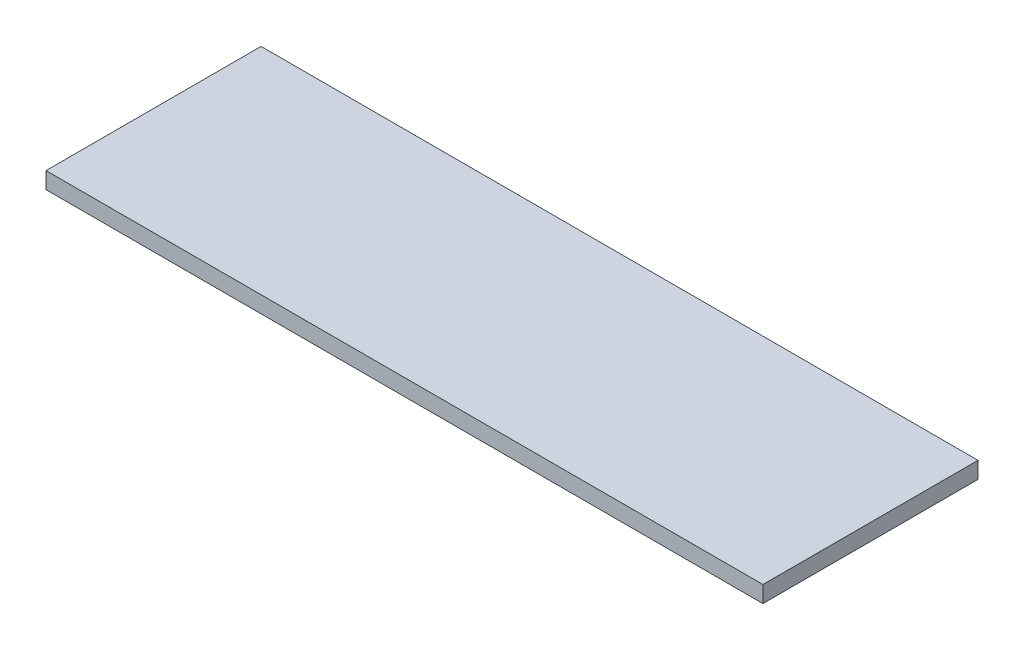
from build123d import *

# Parameters (mm, degrees)
SKETCH1_W           = 130
SKETCH1_H           = 39
BOSS_EXTRUDE1_DEPTH = 3


with BuildPart() as part:
    # Sketch1 → Boss-Extrude1 (new body)
    with BuildSketch(Plane(origin=(0, 0, 0), x_dir=(1, 0, 0), z_dir=(0, 1, 0))):
        with Locations((65, 16.610835058)):
            Rectangle(SKETCH1_W, SKETCH1_H)
    extrude(amount=BOSS_EXTRUDE1_DEPTH)


solid = part.part
